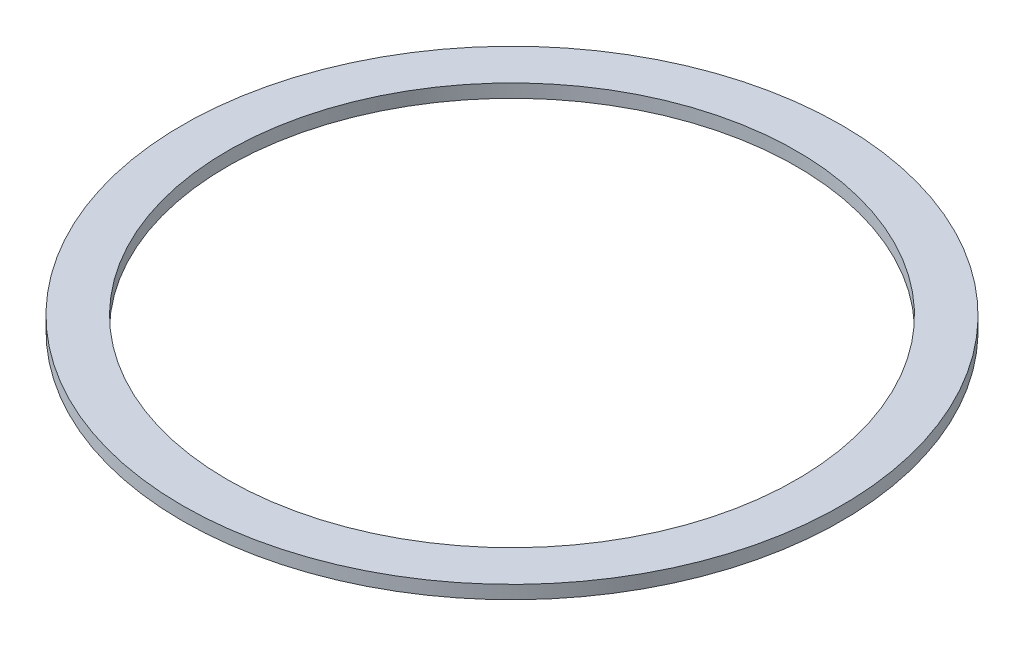
from build123d import *

# Parameters (mm, degrees)
ESBO_O1_R                = 99
ESBO_O1_R_2              = 85.5
RESSALTO_EXTRUS_O1_DEPTH = 4


with BuildPart() as part:
    # Esboço1 → Ressalto-extrusão1 (new body)
    with BuildSketch(Plane(origin=(0, 0, 0), x_dir=(1, 0, 0), z_dir=(0, 1, 0))):
        Circle(ESBO_O1_R)
        Circle(ESBO_O1_R_2, mode=Mode.SUBTRACT)
    extrude(amount=RESSALTO_EXTRUS_O1_DEPTH)


solid = part.part
